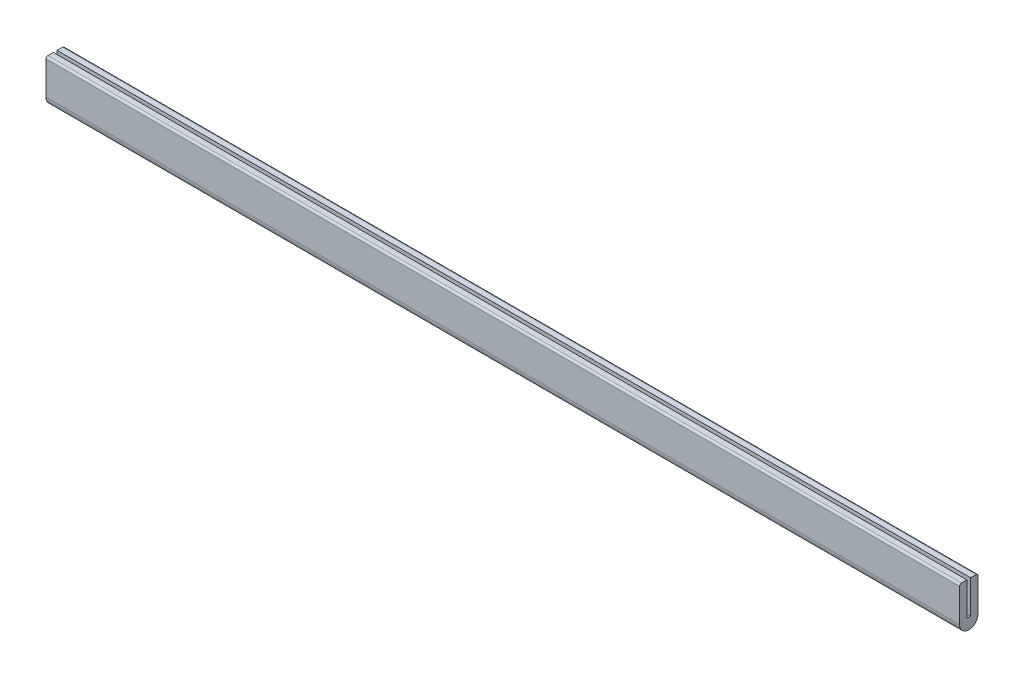
from build123d import *

# Parameters (mm, degrees)
BOSS_EXTRUDE1_DEPTH = 393.7
FILLET1_R           = 1.5875


with BuildPart() as part:
    # Sketch1 → Boss-Extrude1 (new body, symmetric)
    with BuildSketch(Plane(origin=(0, 0, 0), x_dir=(0, 0, -1), z_dir=(1, 0, 0))):
        with BuildLine():
            Line((-1.5875, 28.575), (-7.9375, 28.575))
            Line((-7.9375, 28.575), (-7.9375, -1.5875))
            ThreePointArc((-7.9375, -1.5875), (0, -9.525), (7.9375, -1.5875))
            Line((7.9375, -1.5875), (7.9375, 28.575))
            Line((7.9375, 28.575), (1.5875, 28.575))
            Line((1.5875, 28.575), (1.5875, 0))
            Line((1.5875, 0), (-1.5875, 0))
            Line((-1.5875, 0), (-1.5875, 28.575))
        make_face()
    extrude(amount=BOSS_EXTRUDE1_DEPTH, both=True)

    # Fillet1
    fillet1_edges = [part.edges().sort_by_distance(p)[0] for p in [
        (0, 28.575, -7.9375),
        (0, 28.575, 7.9375),
    ]]
    fillet(fillet1_edges, radius=FILLET1_R)


solid = part.part
